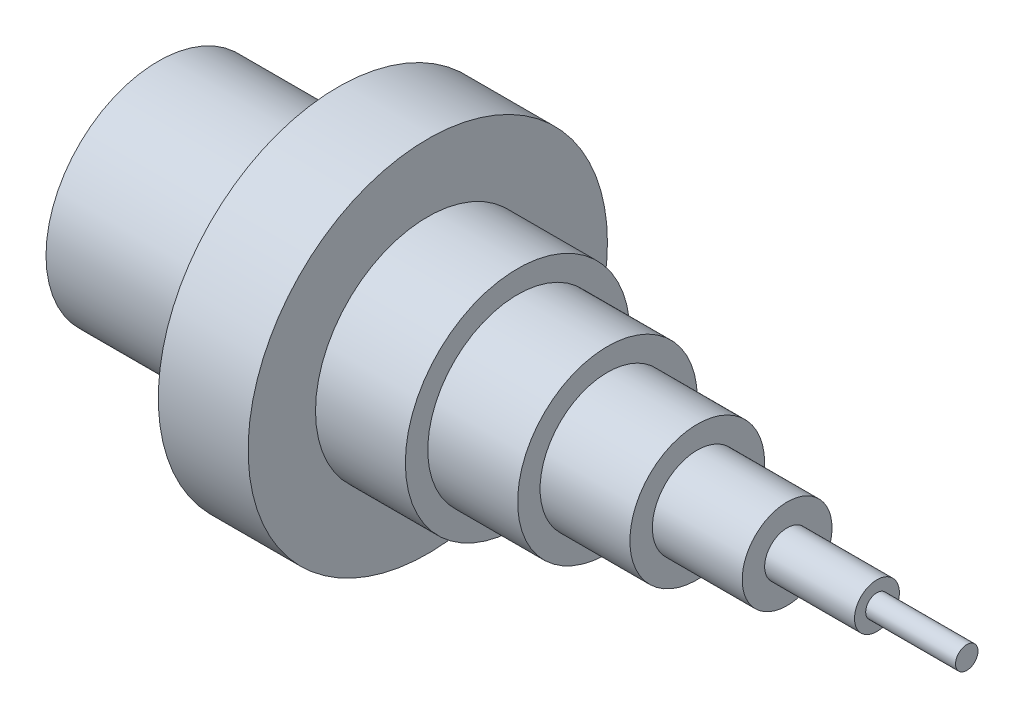
from build123d import *

# Parameters (mm, degrees)
SKETCH1_R           = 25
BOSS_EXTRUDE1_DEPTH = 40
SKETCH2_R           = 20
CUT_EXTRUDE1_DEPTH  = 70
SKETCH9_R           = 2.5
BOSS_EXTRUDE2_DEPTH = 20
SKETCH3_R           = 40
BOSS_EXTRUDE3_DEPTH = 20
SKETCH4_R           = 25
BOSS_EXTRUDE4_DEPTH = 20
SKETCH5_R           = 20
BOSS_EXTRUDE5_DEPTH = 20
SKETCH6_R           = 15
BOSS_EXTRUDE6_DEPTH = 20
SKETCH7_R           = 10
BOSS_EXTRUDE7_DEPTH = 20
SKETCH8_R           = 5
BOSS_EXTRUDE8_DEPTH = 20


with BuildPart() as part:
    # Sketch1 → Boss-Extrude1 (new body)
    with BuildSketch(Plane(origin=(0, 0, 0), x_dir=(0, 0, -1), z_dir=(1, 0, 0))):
        Circle(SKETCH1_R)
    extrude(amount=BOSS_EXTRUDE1_DEPTH)

    # Sketch2 → Cut-Extrude1 (cut)
    with BuildSketch(Plane(origin=(0, 0, 0), x_dir=(0, 0, -1), z_dir=(1, 0, 0))):
        Circle(SKETCH2_R)
    extrude(amount=CUT_EXTRUDE1_DEPTH, mode=Mode.SUBTRACT)

    # Sketch3 → Boss-Extrude3 (add)
    with BuildSketch(Plane(origin=(40, 0, 0), x_dir=(0, 0, -1), z_dir=(1, 0, 0))):
        Circle(SKETCH3_R)
    extrude(amount=BOSS_EXTRUDE3_DEPTH)

    # Sketch4 → Boss-Extrude4 (add)
    with BuildSketch(Plane(origin=(60, 0, 0), x_dir=(0, 0, -1), z_dir=(1, 0, 0))):
        Circle(SKETCH4_R)
    extrude(amount=BOSS_EXTRUDE4_DEPTH)

    # Sketch5 → Boss-Extrude5 (add)
    with BuildSketch(Plane(origin=(80, 0, 0), x_dir=(0, 0, -1), z_dir=(1, 0, 0))):
        Circle(SKETCH5_R)
    extrude(amount=BOSS_EXTRUDE5_DEPTH)

    # Sketch6 → Boss-Extrude6 (add)
    with BuildSketch(Plane(origin=(100, 0, 0), x_dir=(0, 0, -1), z_dir=(1, 0, 0))):
        Circle(SKETCH6_R)
    extrude(amount=BOSS_EXTRUDE6_DEPTH)

    # Sketch7 → Boss-Extrude7 (add)
    with BuildSketch(Plane(origin=(120, 0, 0), x_dir=(0, 0, -1), z_dir=(1, 0, 0))):
        Circle(SKETCH7_R)
    extrude(amount=BOSS_EXTRUDE7_DEPTH)



with BuildPart() as body_2:
    # Sketch9 → Boss-Extrude2 (new body)
    with BuildSketch(Plane(origin=(160, 0, 0), x_dir=(0, 0, -1), z_dir=(1, 0, 0))):
        Circle(SKETCH9_R)
    extrude(amount=BOSS_EXTRUDE2_DEPTH)


with BuildPart() as part_1:
    add(part.part)

    add(body_2.part)  # Boss-Extrude8 merges body 2
    # Sketch8 → Boss-Extrude8 (add)
    with BuildSketch(Plane(origin=(140, 0, 0), x_dir=(0, 0, -1), z_dir=(1, 0, 0))):
        Circle(SKETCH8_R)
    extrude(amount=BOSS_EXTRUDE8_DEPTH)


solid = part_1.part
